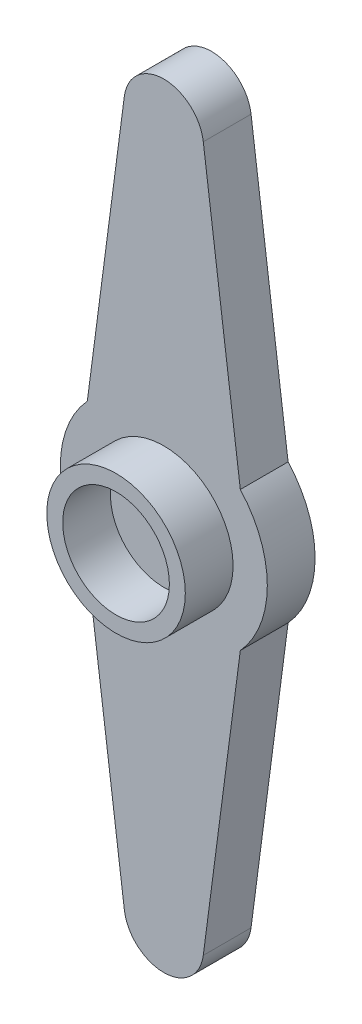
from build123d import *

# Parameters (mm, degrees)
EXTRUDE_1_DEPTH   = 3
SKETCH_2_R        = 4.35
SKETCH_2_R_2      = 3.35
EXTRUDE_1_2_DEPTH = 3


with BuildPart() as part:
    # 草图1 → Extrude 1 (new body)
    with BuildSketch(Plane.XY):
        with BuildLine():
            Line((-2.478800796, 22.124879382), (-4.804808177, 4.37764987))
            ThreePointArc((-4.804808177, 4.37764987), (-6.5, 0), (-4.804808177, -4.37764987))
            Line((-4.804808177, -4.37764987), (-2.478800796, -22.124879382))
            ThreePointArc((-2.478800796, -22.124879382), (0, -24.3), (2.478800796, -22.124879382))
            Line((2.478800796, -22.124879382), (4.804808177, -4.37764987))
            ThreePointArc((4.804808177, -4.37764987), (6.5, 0), (4.804808177, 4.37764987))
            Line((4.804808177, 4.37764987), (2.478800796, 22.124879382))
            ThreePointArc((2.478800796, 22.124879382), (0, 24.3), (-2.478800796, 22.124879382))
        make_face()
    extrude(amount=EXTRUDE_1_DEPTH)

    # 草图2 → Extrude 1 2 (add)
    with BuildSketch(Plane.XY.offset(3)):
        Circle(SKETCH_2_R)
        Circle(SKETCH_2_R_2, mode=Mode.SUBTRACT)
    extrude(amount=EXTRUDE_1_2_DEPTH)


solid = part.part
